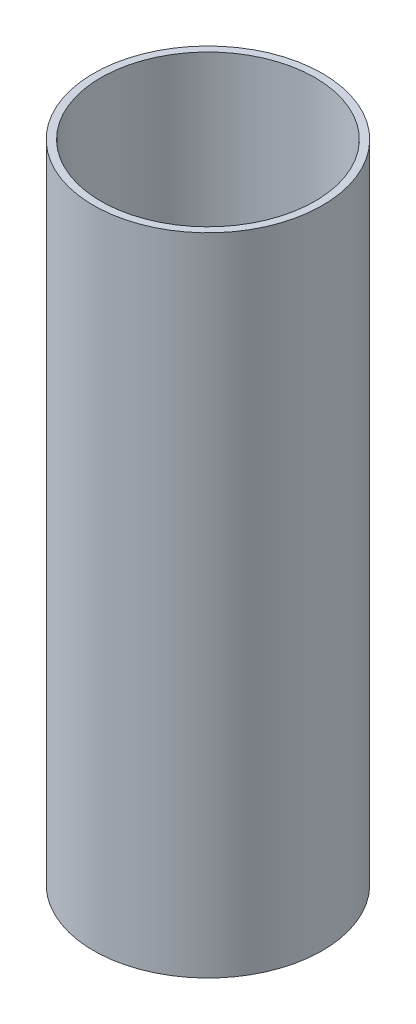
from build123d import *

# Parameters (mm, degrees)
SKETCH1_W = 3.175
SKETCH1_H = 279.4


with BuildPart() as part:
    # Sketch1 → Revolve1 (revolve)
    with BuildSketch(Plane.XY):
        with Locations((47.9425, 139.7)):
            Rectangle(SKETCH1_W, SKETCH1_H)
    revolve(axis=Axis((0, -13.97, 0), (0, 1, 0)))


solid = part.part
